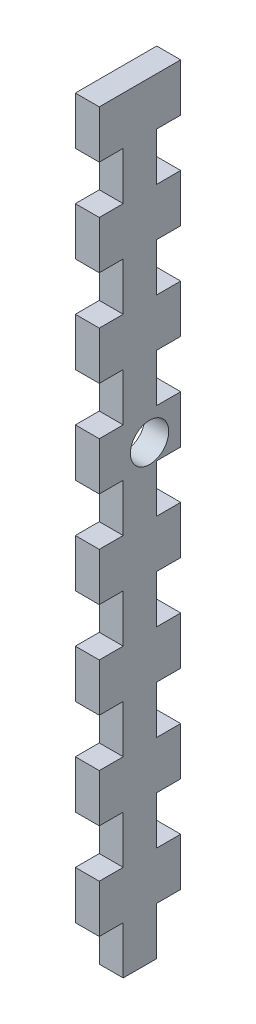
from build123d import *

# Parameters (mm, degrees)
SALIENTE_EXTRUIR1_DEPTH = 5
CROQUIS2_R              = 4
CORTAR_EXTRUIR1_DEPTH   = 5


with BuildPart() as part:
    # Croquis1 → Saliente-Extruir1 (new body)
    with BuildSketch(Plane(origin=(0, 0, 0), x_dir=(0, 0, -1), z_dir=(1, 0, 0))):
        Polygon((-17.15051747, 72.789115646), (-17.15051747, 62.789115646), (-12.15051747, 62.789115646), (-12.15051747, 52.789115646), (-17.15051747, 52.789115646), (-17.15051747, 42.789115646), (-12.15051747, 42.789115646), (-12.15051747, 32.789115646), (-17.15051747, 32.789115646), (-17.15051747, 22.789115646), (-12.15051747, 22.789115646), (-12.15051747, 12.789115646), (-17.15051747, 12.789115646), (-17.15051747, 2.789115646), (-12.15051747, 2.789115646), (-12.15051747, -7.210884354), (-17.15051747, -7.210884354), (-17.15051747, -17.210884354), (-12.15051747, -17.210884354), (-12.15051747, -27.210884354), (-17.15051747, -27.210884354), (-17.15051747, -37.210884354), (-12.15051747, -37.210884354), (-12.15051747, -47.210884354), (-17.15051747, -47.210884354), (-17.15051747, -57.210884354), (-12.15051747, -57.210884354), (-12.15051747, -67.210884354), (-5.15051747, -67.210884354), (-5.15051747, -57.210884354), (-0.15051747, -57.210884354), (-0.15051747, -47.210884354), (-5.15051747, -47.210884354), (-5.15051747, -37.210884354), (-0.15051747, -37.210884354), (-0.15051747, -27.210884354), (-5.15051747, -27.210884354), (-5.15051747, -17.210884354), (-0.15051747, -17.210884354), (-0.15051747, -7.210884354), (-5.15051747, -7.210884354), (-5.15051747, 2.789115646), (-0.15051747, 2.789115646), (-0.15051747, 12.789115646), (-5.15051747, 12.789115646), (-5.15051747, 22.789115646), (-0.15051747, 22.789115646), (-0.15051747, 32.789115646), (-5.15051747, 32.789115646), (-5.15051747, 42.789115646), (-0.15051747, 42.789115646), (-0.15051747, 52.789115646), (-5.15051747, 52.789115646), (-5.15051747, 62.789115646), (-0.15051747, 62.789115646), (-0.15051747, 72.789115646), (-5.15051747, 72.789115646), (-5.15051747, 82.789115646), (-0.15051747, 82.789115646), (-0.15051747, 92.789115646), (-17.15051747, 92.789115646), (-17.15051747, 82.789115646), (-12.15051747, 82.789115646), (-12.15051747, 72.789115646), align=None)
    extrude(amount=SALIENTE_EXTRUIR1_DEPTH)

    # Croquis2 → Cortar-Extruir1 (cut)
    with BuildSketch(Plane(origin=(5, 0, 0), x_dir=(0, 0, -1), z_dir=(1, 0, 0))):
        with Locations((-6.65051747, 26.874115646)):
            Circle(CROQUIS2_R)
    extrude(amount=-CORTAR_EXTRUIR1_DEPTH, mode=Mode.SUBTRACT)


solid = part.part
